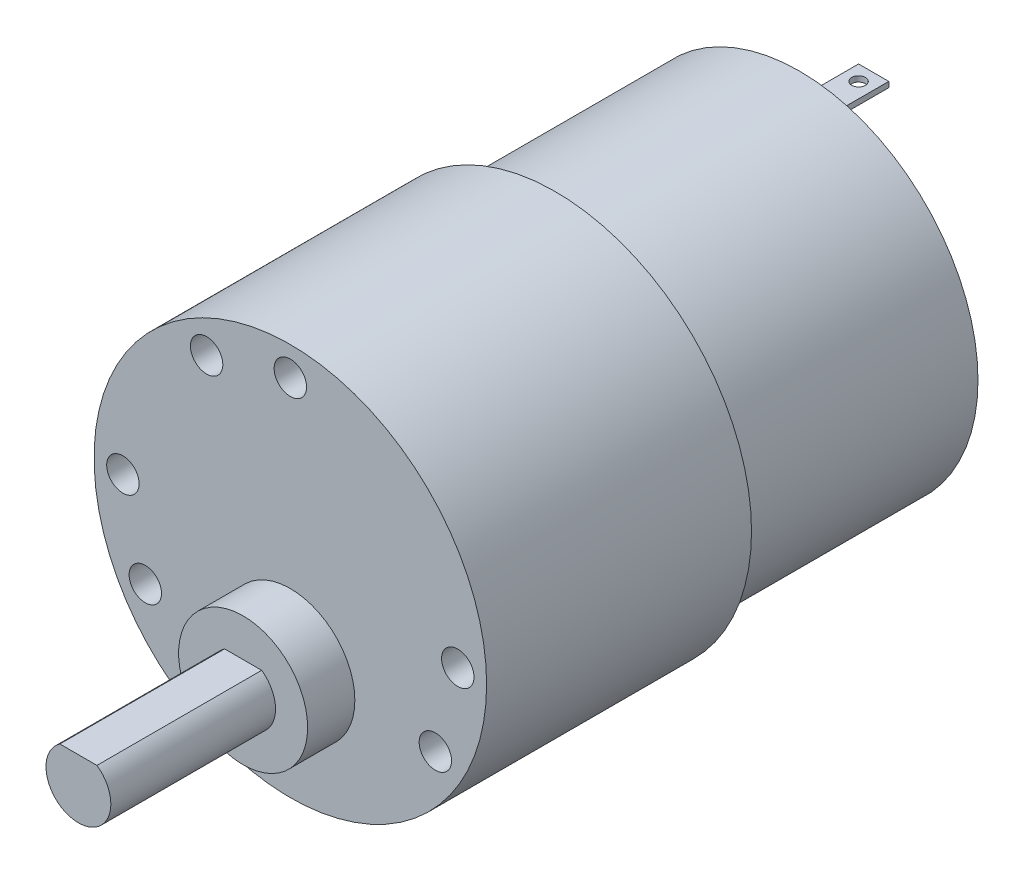
from build123d import *

# Parameters (mm, degrees)
SKETCH1_R           = 18.161
BOSS_EXTRUDE1_DEPTH = 24.511
SKETCH2_R           = 16.51
BOSS_EXTRUDE2_DEPTH = 22.606
SKETCH3_R           = 4.5085
BOSS_EXTRUDE3_DEPTH = 3.302
SKETCH4_R           = 2.413
BOSS_EXTRUDE4_DEPTH = 1.27
SKETCH5_R           = 5.969
BOSS_EXTRUDE5_DEPTH = 4.3688
BOSS_EXTRUDE6_DEPTH = 15.24
SKETCH8_W           = 5.588
SKETCH8_H           = 2.794
SKETCH8_R           = 0.635
BOSS_EXTRUDE7_DEPTH = 0.254
CIRPATTERN1_COUNT   = 2
CIRPATTERN2_COUNT   = 12


with BuildPart() as part:
    # Sketch1 → Boss-Extrude1 (new body)
    with BuildSketch(Plane.XY):
        Circle(SKETCH1_R)
    extrude(amount=BOSS_EXTRUDE1_DEPTH)

    # Sketch2 → Boss-Extrude2 (add)
    with BuildSketch(Plane(origin=(0, 0, 0), x_dir=(-1, 0, 0), z_dir=(0, 0, -1))):
        Circle(SKETCH2_R)
    extrude(amount=BOSS_EXTRUDE2_DEPTH)

    # Sketch3 → Boss-Extrude3 (add)
    with BuildSketch(Plane(origin=(0, 0, -22.606), x_dir=(-1, 0, 0), z_dir=(0, 0, -1))):
        Circle(SKETCH3_R)
    extrude(amount=BOSS_EXTRUDE3_DEPTH)

    # Sketch4 → Boss-Extrude4 (add)
    with BuildSketch(Plane(origin=(0, 0, -22.606), x_dir=(-1, 0, 0), z_dir=(0, 0, -1))):
        with Locations((0, -12.7)):
            Circle(SKETCH4_R)
        with Locations((0, 12.7)):
            Circle(SKETCH4_R)
    extrude(amount=BOSS_EXTRUDE4_DEPTH)

    # Sketch5 → Boss-Extrude5 (add)
    with BuildSketch(Plane.XY.offset(24.511)):
        with Locations((0, -7.366)):
            Circle(SKETCH5_R)
    extrude(amount=BOSS_EXTRUDE5_DEPTH)

    # Sketch6 → Boss-Extrude6 (add)
    with BuildSketch(Plane.XY.offset(28.8798)):
        with BuildLine():
            Line((-1.715657017, -4.905), (1.715657017, -4.905))
            ThreePointArc((1.715657017, -4.905), (0, -10.366), (-1.715657017, -4.905))
        make_face()
    extrude(amount=BOSS_EXTRUDE6_DEPTH)

    # Sketch8 → Boss-Extrude7 (add, symmetric)
    with BuildSketch(Plane.ZX.offset(12.7)):
        with Locations((-26.67, 0)):
            Rectangle(SKETCH8_W, SKETCH8_H)
        with Locations((-28.067, 0)):
            Circle(SKETCH8_R, mode=Mode.SUBTRACT)
    boss_extrude7 = extrude(amount=BOSS_EXTRUDE7_DEPTH, both=True)

    # CirPattern1: Boss-Extrude7 ×2 about axis
    cirpattern1_axis = Axis((0, 0, -25.908), (0, 0, 1))
    for i in range(1, CIRPATTERN1_COUNT):
        add(boss_extrude7.rotate(cirpattern1_axis, i * 360 / CIRPATTERN1_COUNT))

    # Sketch12 → Ø3.0mm Dowel Hole1 (revolve, cut)
    with BuildSketch(Plane(origin=(0, 15.494, 24.511), x_dir=(0, -1, 0), z_dir=(1, 0, 0))):
        Polygon((0, 0), (0, 11.061290929), (1.5, 10.16), (1.5, 0), align=None)
    f_3_0mm_dowel_hole1 = revolve(axis=Axis((0, 15.494, 30.861), (0, 0, -1)), mode=Mode.SUBTRACT)

    # CirPattern2: Ø3.0mm Dowel Hole1 ×12 about axis, 5 skipped
    cirpattern2_axis = Axis((0, 0, 24.511), (0, 0, -1))
    add([f_3_0mm_dowel_hole1.rotate(cirpattern2_axis, i * 360 / CIRPATTERN2_COUNT) for i in range(1, CIRPATTERN2_COUNT) if i not in (1, 2, 5, 6, 10)], mode=Mode.SUBTRACT)


solid = part.part
